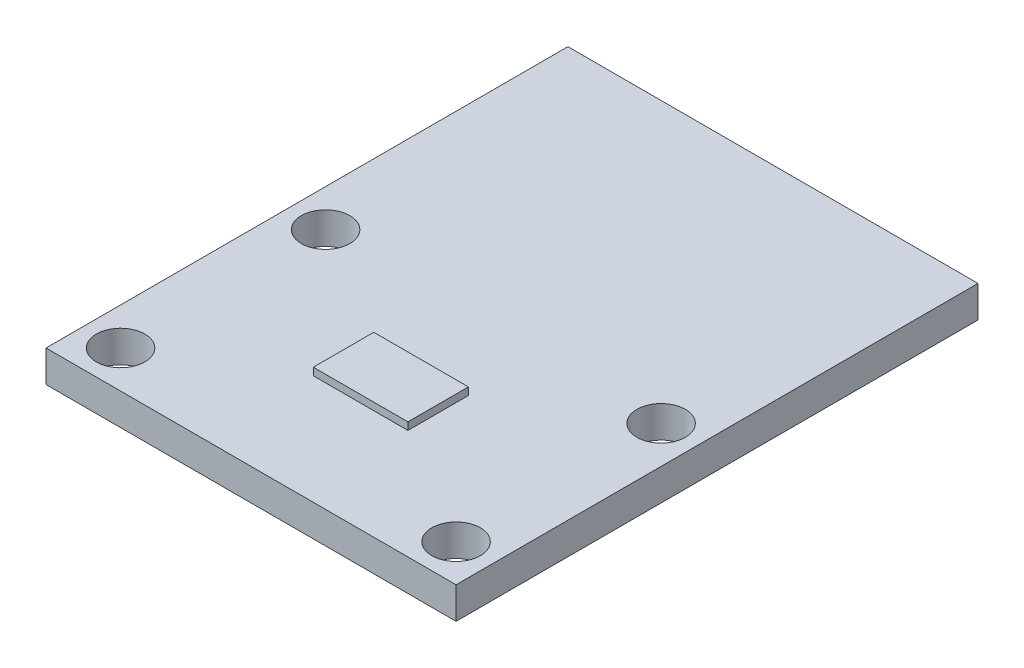
from build123d import *

# Parameters (mm, degrees)
SKETCH1_W           = 22
SKETCH1_H           = 28
SKETCH1_R           = 1.3
BOSS_EXTRUDE1_DEPTH = 1.7
SKETCH2_W           = 5.076537092
SKETCH2_H           = 3.244918692
BOSS_EXTRUDE2_DEPTH = 0.4


with BuildPart() as part:
    # Sketch1 → Boss-Extrude1 (new body)
    with BuildSketch(Plane(origin=(0, 0, 0), x_dir=(1, 0, 0), z_dir=(0, 1, 0))):
        Rectangle(SKETCH1_W, SKETCH1_H)
        with Locations((9, -1)):
            Circle(SKETCH1_R, mode=Mode.SUBTRACT)
        with Locations((9, -12)):
            Circle(SKETCH1_R, mode=Mode.SUBTRACT)
        with Locations((-9, -1)):
            Circle(SKETCH1_R, mode=Mode.SUBTRACT)
        with Locations((-9, -12)):
            Circle(SKETCH1_R, mode=Mode.SUBTRACT)
    extrude(amount=BOSS_EXTRUDE1_DEPTH)

    # Sketch2 → Boss-Extrude2 (add)
    with BuildSketch(Plane(origin=(0, 1.7, 0), x_dir=(1, 0, 0), z_dir=(0, 1, 0))):
        with Locations((0, -6.5)):
            Rectangle(SKETCH2_W, SKETCH2_H)
    extrude(amount=BOSS_EXTRUDE2_DEPTH)


solid = part.part
